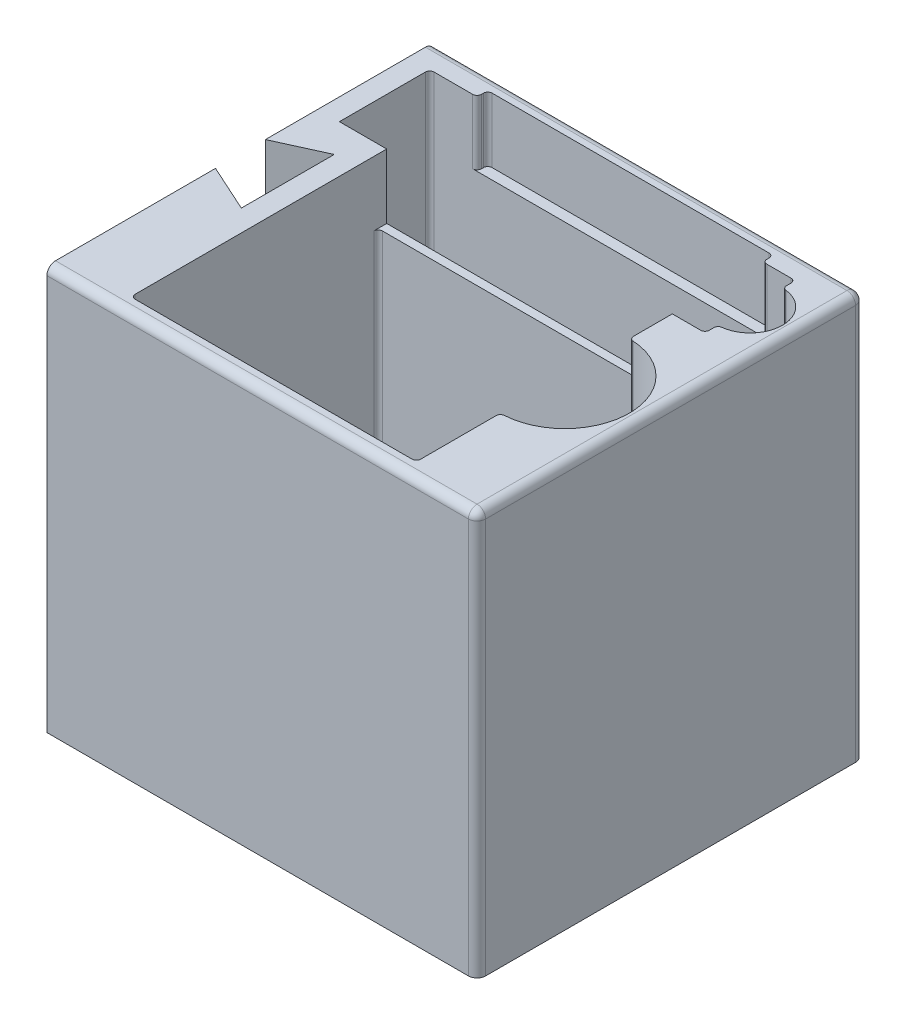
from build123d import *

# Parameters (mm, degrees)
BOSS_EXTRUDE1_DEPTH = 119.38
CUT_EXTRUDE1_DEPTH  = 115.57
SKETCH5_W           = 84.328
SKETCH5_H           = 105.41
CUT_EXTRUDE4_DEPTH  = 19.05
CUT_EXTRUDE5_START  = -24.13
CUT_EXTRUDE5_DEPTH  = 43.18
CUT_EXTRUDE6_DEPTH  = 43.18
FILLET2_R           = 2.54
FILLET3_R           = 1.27


with BuildPart() as part:
    # Sketch1 → Boss-Extrude1 (new body)
    with BuildSketch(Plane(origin=(0, 0, 0), x_dir=(1, 0, 0), z_dir=(0, 1, 0))):
        Polygon((0, 64.516), (13.97, 70.866), (13.97, 43.434), (0, 49.784), (0, 0), (127, 0), (127, 114.3), (0, 114.3), align=None)
    extrude(amount=BOSS_EXTRUDE1_DEPTH)

    # Sketch2 → Cut-Extrude1 (cut)
    with BuildSketch(Plane(origin=(0, 119.38, 0), x_dir=(1, 0, 0), z_dir=(0, 1, 0))):
        with BuildLine():
            Line((20.32, 77.47), (104.648, 77.47))
            Line((104.648, 77.47), (104.648, 67.31))
            ThreePointArc((104.648, 67.31), (123.698, 48.26), (104.648, 29.21))
            Line((104.648, 29.21), (104.648, 19.05))
            Line((104.648, 19.05), (20.32, 19.05))
            Line((20.32, 19.05), (20.32, 77.47))
        make_face()
    extrude(amount=-CUT_EXTRUDE1_DEPTH, mode=Mode.SUBTRACT)

    # Sketch5 → Cut-Extrude4 (cut)
    with BuildSketch(Plane(origin=(0, 119.38, 0), x_dir=(1, 0, 0), z_dir=(0, 1, 0))):
        with Locations((62.484, 57.15)):
            Rectangle(SKETCH5_W, SKETCH5_H)
    extrude(amount=-CUT_EXTRUDE4_DEPTH, mode=Mode.SUBTRACT)

    # Sketch6 → Cut-Extrude5 (cut)
    with BuildSketch(Plane(origin=(0, 100.33, 0), x_dir=(1, 0, 0), z_dir=(0, 1, 0)).offset(CUT_EXTRUDE5_START)):
        with BuildLine():
            Line((6.35, 106.68), (114.3, 106.68))
            Line((114.3, 106.68), (114.3, 102.87))
            ThreePointArc((114.3, 102.87), (123.823120388, 93.346879612), (114.3, 83.823759224))
            Line((114.3, 83.823759224), (114.3, 80.01))
            Line((114.3, 80.01), (6.35, 80.01))
            Line((6.35, 80.01), (6.35, 106.68))
        make_face()
    extrude(amount=CUT_EXTRUDE5_DEPTH, mode=Mode.SUBTRACT)

    # Sketch6_2 → Cut-Extrude6 (cut)
    with BuildSketch(Plane(origin=(0, 100.33, 0), x_dir=(1, 0, 0), z_dir=(0, 1, 0))):
        with BuildLine():
            Line((6.35, 106.68), (114.3, 106.68))
            Line((114.3, 106.68), (114.3, 102.87))
            ThreePointArc((114.3, 102.87), (123.823120388, 93.346879612), (114.3, 83.823759224))
            Line((114.3, 83.823759224), (114.3, 80.01))
            Line((114.3, 80.01), (6.35, 80.01))
            Line((6.35, 80.01), (6.35, 106.68))
        make_face()
    extrude(amount=-CUT_EXTRUDE6_DEPTH, mode=Mode.SUBTRACT)

    # Fillet2
    fillet2_edges = [part.edges().sort_by_distance(p)[0] for p in [
        (127, 119.38, -57.15),
        (127, 59.69, -114.3),
        (127, 59.69, 0),
        (63.5, 119.38, -114.3),
        (63.5, 119.38, 0),
    ]]
    fillet(fillet2_edges, radius=FILLET2_R)

    # Fillet3
    fillet3_edges = [part.edges().sort_by_distance(p)[0] for p in [
        (20.32, 52.07, -19.05),
        (20.32, 52.07, -77.47),
        (104.648, 61.595, -67.31),
        (104.648, 61.595, -29.21),
        (104.648, 52.07, -19.05),
        (20.32, 109.855, -4.445),
        (104.648, 109.855, -109.855),
        (20.32, 109.855, -109.855),
        (104.648, 109.855, -4.445),
        (104.648, 109.855, -106.68),
        (6.35, 88.265, -106.68),
        (20.32, 109.855, -106.68),
        (114.3, 88.265, -106.68),
        (114.3, 88.265, -102.87),
        (114.3, 88.265, -83.823759224),
        (114.3, 88.265, -80.01),
    ]]
    fillet(fillet3_edges, radius=FILLET3_R)


solid = part.part
